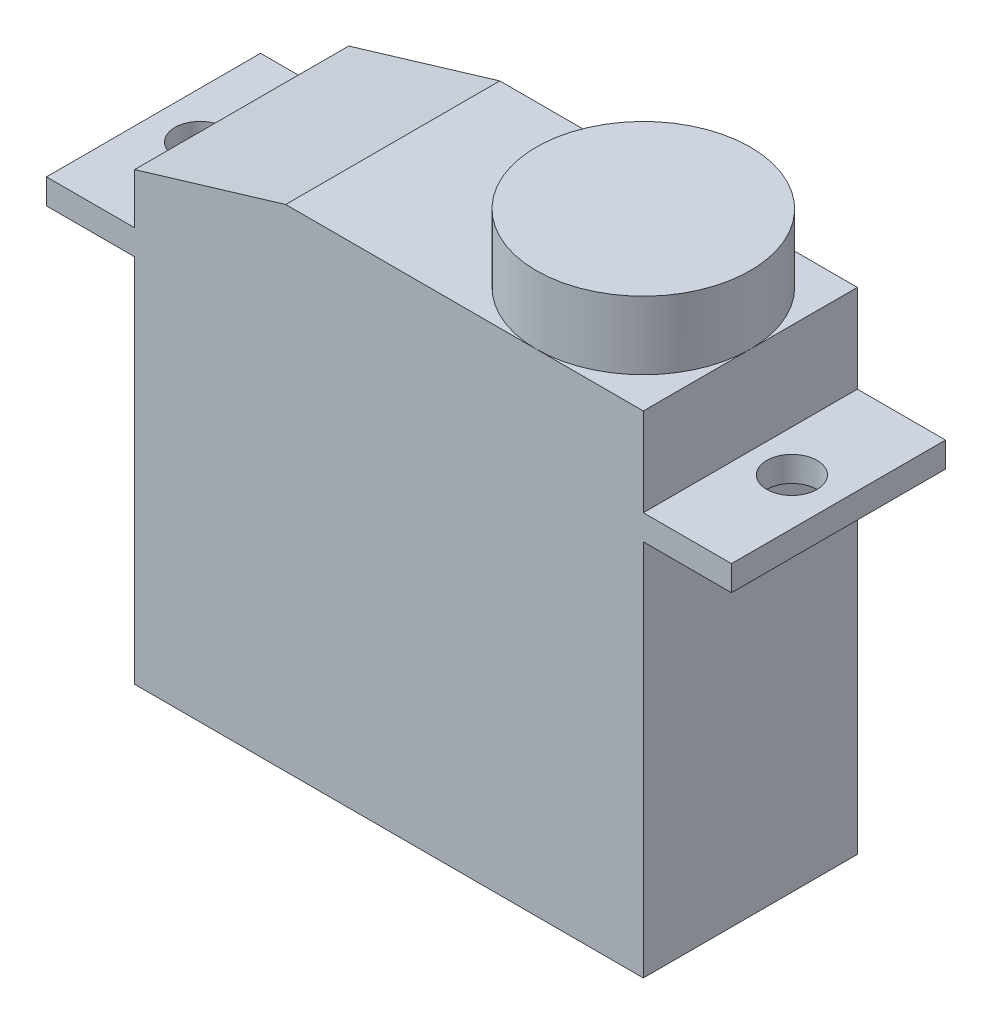
from build123d import *

# Parameters (mm, degrees)
BOSS_EXTRUDE1_DEPTH     = 8.5
SKETCH2_R               = 4.25
BOSS_EXTRUDE2_DEPTH     = 2.7
SKETCH3_R               = 1
CUT_EXTRUDE1_DEPTH      = 7.5
CUT_EXTRUDE1_DEPTH_BACK = 16.7


with BuildPart() as part:
    # Sketch1 → Boss-Extrude1 (new body)
    with BuildSketch(Plane.XY):
        Polygon((0, 0), (-20.2, 0), (-20.2, 14.7), (-23.7, 14.7), (-23.7, 15.7), (-20.2, 15.7), (-20.2, 17.7), (-14.2, 19.5), (0, 19.5), (0, 16), (3.5, 16), (3.5, 15), (0, 15), align=None)
    extrude(amount=BOSS_EXTRUDE1_DEPTH)

    # Sketch2 → Boss-Extrude2 (add)
    with BuildSketch(Plane(origin=(0, 19.5, 0), x_dir=(1, 0, 0), z_dir=(0, 1, 0))):
        with Locations((-4.25, -4.25)):
            Circle(SKETCH2_R)
    extrude(amount=BOSS_EXTRUDE2_DEPTH)

    # Sketch3 → Cut-Extrude1 (cut, two sides)
    with BuildSketch(Plane(origin=(0, 15.7, 0), x_dir=(1, 0, 0), z_dir=(0, 1, 0))) as cut_extrude1_sk:
        with Locations((-21.85, -4.25)):
            Circle(SKETCH3_R)
        with Locations((1.65, -4.25)):
            Circle(SKETCH3_R)
    extrude(amount=CUT_EXTRUDE1_DEPTH, mode=Mode.SUBTRACT)
    extrude(cut_extrude1_sk.sketch, amount=-CUT_EXTRUDE1_DEPTH_BACK, mode=Mode.SUBTRACT)


solid = part.part
